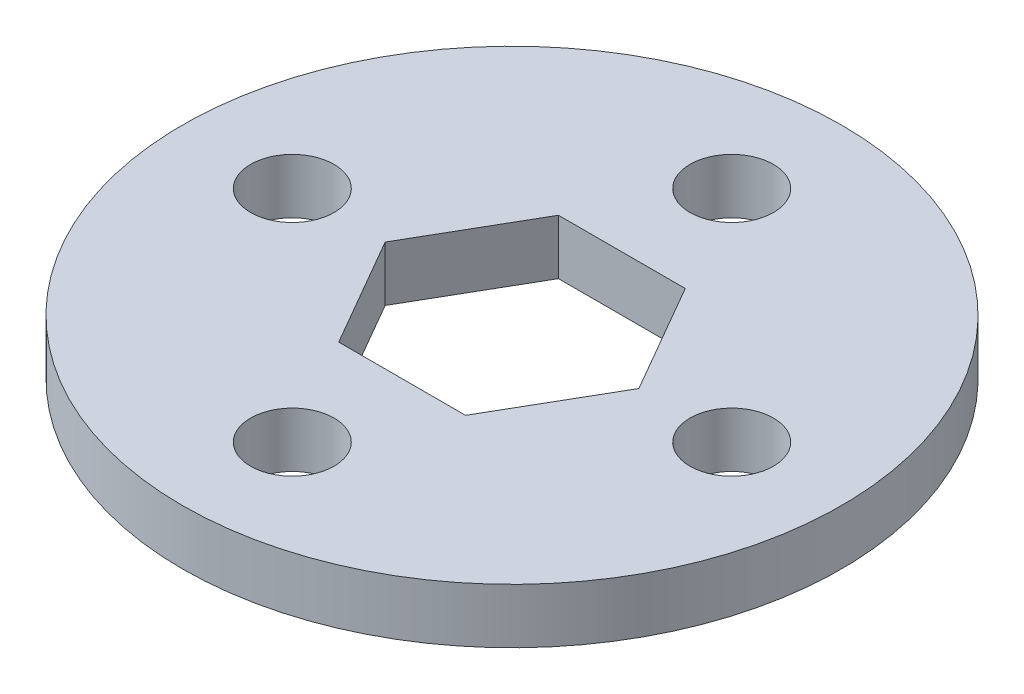
from build123d import *

# Parameters (mm, degrees)
SKETCH1_R           = 19.05
SKETCH1_R_2         = 2.413
BOSS_EXTRUDE1_DEPTH = 3.175


with BuildPart() as part:
    # Sketch1 → Boss-Extrude1 (new body)
    with BuildSketch(Plane(origin=(0, 0, 0), x_dir=(1, 0, 0), z_dir=(0, 1, 0))):
        Circle(SKETCH1_R)
        with Locations((0, 12.7)):
            Circle(SKETCH1_R_2, mode=Mode.SUBTRACT)
        with Locations((12.7, 0)):
            Circle(SKETCH1_R_2, mode=Mode.SUBTRACT)
        with Locations((0, -12.7)):
            Circle(SKETCH1_R_2, mode=Mode.SUBTRACT)
        with Locations((-12.7, 0)):
            Circle(SKETCH1_R_2, mode=Mode.SUBTRACT)
        Polygon((-7.332348419, 0), (-3.666174209, -6.35), (3.666174209, -6.35), (7.332348419, 0), (3.666174209, 6.35), (-3.666174209, 6.35), align=None, mode=Mode.SUBTRACT)
    extrude(amount=BOSS_EXTRUDE1_DEPTH)


solid = part.part
